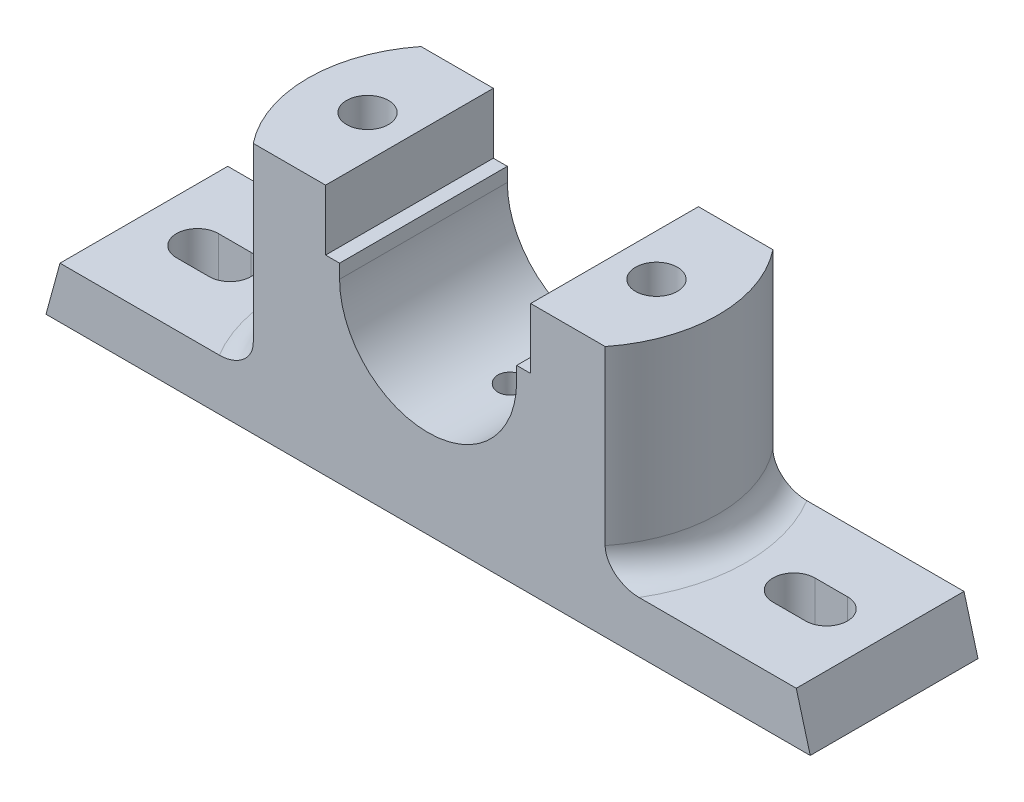
from build123d import *

# Parameters (mm, degrees)
BOSS_EXTRUDE2_DEPTH       = 36
CUT_EXTRUDE1_DEPTH        = 43
FILLET1_R                 = 6
CUT_EXTRUDE2_DEPTH        = 43
FILLET2_R                 = 6
F_6_0MM_DOWEL_HOLE1_D     = 6
F_6_0MM_DOWEL_HOLE1_DEPTH = 6
F_6_0MM_DOWEL_HOLE1_TIP   = 1.802581857
SKETCH23_W                = 20
SKETCH23_H                = 20
CUT_EXTRUDE4_DEPTH        = 8
CUT_EXTRUDE5_DEPTH        = 12.0000001


with BuildPart() as part:
    # Sketch1 → Boss-Extrude2 (new body)
    with BuildSketch(Plane.XY):
        with BuildLine():
            Line((50, -27), (79, -27))
            Line((79, -27), (82, -38))
            Line((82, -38), (-82, -38))
            Line((-82, -38), (-79, -27))
            Line((-79, -27), (-50, -27))
            Line((-50, -27), (-50, 16))
            Line((-50, 16), (-22, 16))
            Line((-22, 16), (-22, 3))
            Line((-22, 3), (-19, 3))
            Line((-19, 3), (-19, 0))
            ThreePointArc((-19, 0), (0, -19), (19, 0))
            Line((19, 0), (19, 3))
            Line((19, 3), (22, 3))
            Line((22, 3), (22, 16))
            Line((22, 16), (50, 16))
            Line((50, 16), (50, -27))
        make_face()
    extrude(amount=BOSS_EXTRUDE2_DEPTH)

    # Sketch11 → Cut-Extrude1 (cut)
    with BuildSketch(Plane(origin=(0, 16, 0), x_dir=(1, 0, 0), z_dir=(0, 1, 0))):
        with BuildLine():
            Line((-50, 0), (-50, -36))
            Line((-50, -36), (-37.523326079, -36))
            ThreePointArc((-37.523326079, -36), (-43.785692077, -18), (-37.523326079, 0))
            Line((-37.523326079, 0), (-50, 0))
        make_face()
    extrude(amount=-CUT_EXTRUDE1_DEPTH, mode=Mode.SUBTRACT)

    # Fillet1
    fillet1_edges = [part.edges().sort_by_distance(p)[0] for p in [
        (-43.785692077, -27, 18),
    ]]
    fillet(fillet1_edges, radius=FILLET1_R)

    # Sketch12 → Cut-Extrude2 (cut)
    with BuildSketch(Plane(origin=(0, 16, 0), x_dir=(1, 0, 0), z_dir=(0, 1, 0))):
        with BuildLine():
            Line((37.994971795, 0), (50, 0))
            Line((50, 0), (50, -36))
            Line((50, -36), (37.994971795, -36))
            ThreePointArc((37.994971795, -36), (44.257337793, -18), (37.994971795, 0))
        make_face()
    extrude(amount=-CUT_EXTRUDE2_DEPTH, mode=Mode.SUBTRACT)

    # Fillet2
    fillet2_edges = [part.edges().sort_by_distance(p)[0] for p in [
        (44.257337793, -27, 18),
    ]]
    fillet(fillet2_edges, radius=FILLET2_R)

    # Ø6.0mm Dowel Hole1
    with Locations(Plane(origin=(0, -19, 18), x_dir=(1, 0, 0), z_dir=(0, 1, 0))):
        with Locations((0, 0)):
            Hole(F_6_0MM_DOWEL_HOLE1_D / 2, depth=F_6_0MM_DOWEL_HOLE1_DEPTH)
            with Locations((0, 0, -(F_6_0MM_DOWEL_HOLE1_DEPTH + F_6_0MM_DOWEL_HOLE1_TIP / 2))):  # 118° drill point
                Cone(0, F_6_0MM_DOWEL_HOLE1_D / 2, F_6_0MM_DOWEL_HOLE1_TIP, mode=Mode.SUBTRACT)

    # Sketch19 → Ø6.0mm Dowel Hole3 (revolve, cut)
    with BuildSketch(Plane(origin=(-31, 16, 18), x_dir=(0, 0, 1), z_dir=(1, 0, 0))):
        Polygon((0, 0), (0, 48.703872786), (4.5, 46), (4.5, 0), align=None)
    f_6_0mm_dowel_hole3 = revolve(axis=Axis((-31, 22.35, 18), (0, -1, 0)), mode=Mode.SUBTRACT)

    # Sketch23 → Cut-Extrude4 (cut)
    with BuildSketch(Plane.XZ.offset(38)):
        with Locations((-31, 18)):
            Rectangle(SKETCH23_W, SKETCH23_H)
    cut_extrude4 = extrude(amount=-CUT_EXTRUDE4_DEPTH, mode=Mode.SUBTRACT)

    # Mirror1: Ø6.0mm Dowel Hole3, Cut-Extrude4 across plane
    add(f_6_0mm_dowel_hole3.mirror(Plane(origin=(0, 0, 0), x_dir=(0, 0, 1), z_dir=(1, 0, 0))), mode=Mode.SUBTRACT)
    add(cut_extrude4.mirror(Plane(origin=(0, 0, 0), x_dir=(0, 0, 1), z_dir=(1, 0, 0))), mode=Mode.SUBTRACT)

    # Sketch25 → Cut-Extrude5 (cut, through all)
    with BuildSketch(Plane(origin=(0, -27, 0), x_dir=(1, 0, 0), z_dir=(0, 1, 0))):
        with BuildLine():
            Line((-67.5, -13.5), (-60.5, -13.5))
            ThreePointArc((-60.5, -13.5), (-56, -18), (-60.5, -22.5))
            Line((-60.5, -22.5), (-67.5, -22.5))
            ThreePointArc((-67.5, -22.5), (-72, -18), (-67.5, -13.5))
        make_face()
    cut_extrude5 = extrude(amount=-CUT_EXTRUDE5_DEPTH, mode=Mode.SUBTRACT)

    # Mirror2: Cut-Extrude5 across plane
    add(cut_extrude5.mirror(Plane(origin=(0, 0, 0), x_dir=(0, 0, 1), z_dir=(1, 0, 0))), mode=Mode.SUBTRACT)


solid = part.part
